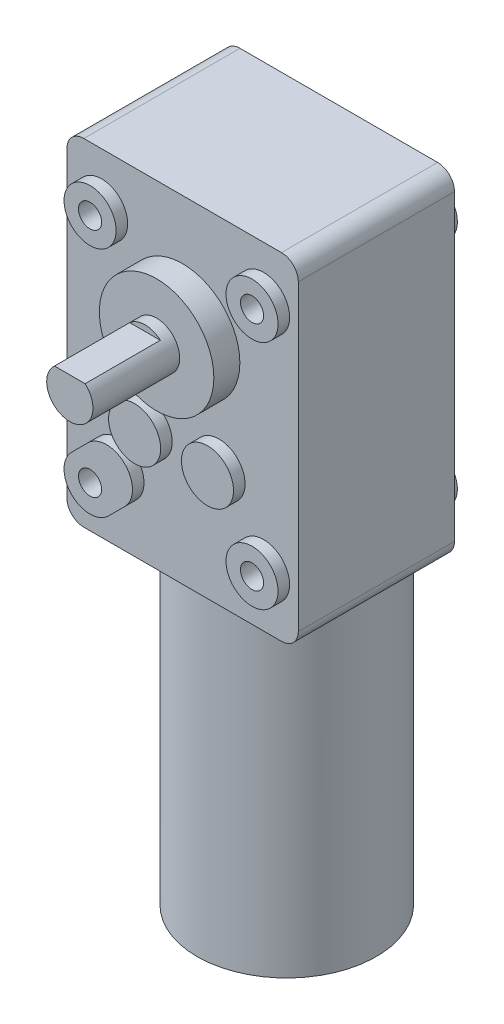
from build123d import *

# Parameters (mm, degrees)
SKETCH1_W           = 40
SKETCH1_H           = 58.200000762
BOSS_EXTRUDE1_DEPTH = 27
SKETCH2_R           = 15.499999921
BOSS_EXTRUDE2_DEPTH = 57
SKETCH3_R           = 9.900000829
BOSS_EXTRUDE3_DEPTH = 4.5
SKETCH4_R           = 3.999999654
BOSS_EXTRUDE4_DEPTH = 15
CUT_EXTRUDE1_DEPTH  = 13
BOSS_EXTRUDE5_DEPTH = 2
BOSS_EXTRUDE6_DEPTH = 2
BOSS_EXTRUDE7_DEPTH = 2
SKETCH9_W           = 4.500000339
SKETCH9_H           = 2
SKETCH10_W          = 4.500000226
SKETCH10_H          = 2
SKETCH11_W          = 4.499999816
SKETCH11_H          = 2
SKETCH12_W          = 4.500000657
SKETCH12_H          = 2
SKETCH13_W          = 4.49999985
SKETCH13_H          = 2
SKETCH14_W          = 9.899999781
SKETCH14_H          = 4.5
SKETCH15_W          = 4.500000004
SKETCH15_H          = 2
SKETCH16_W          = 4.49999905
SKETCH16_H          = 2
SKETCH17_W          = 4.499999637
SKETCH17_H          = 2
SKETCH18_W          = 4.500001132
SKETCH18_H          = 2
SKETCH19_W          = 4.499999489
SKETCH19_H          = 2
FILLET1_R           = 2.913033302
SKETCH20_R          = 2
CUT_EXTRUDE2_DEPTH  = 5


with BuildPart() as part:
    # Sketch1 → Boss-Extrude1 (new body)
    with BuildSketch(Plane(origin=(0, 0, 171), x_dir=(-1, 0, 0), z_dir=(0, 0, -1))):
        with Locations((-152.219146729, 79.232439518)):
            Rectangle(SKETCH1_W, SKETCH1_H)
    extrude(amount=-BOSS_EXTRUDE1_DEPTH)

    # Sketch2 → Boss-Extrude2 (add)
    with BuildSketch(Plane.XZ.offset(-50.132439137)):
        with Locations((152.219146662, 180.000000025)):
            Circle(SKETCH2_R)
    extrude(amount=BOSS_EXTRUDE2_DEPTH)

    # Sketch3 → Boss-Extrude3 (add)
    with BuildSketch(Plane.XY.offset(198)):
        with Locations((152.21914569, 88.232439899)):
            Circle(SKETCH3_R)
    extrude(amount=BOSS_EXTRUDE3_DEPTH)

    # Sketch4 → Boss-Extrude4 (add)
    with BuildSketch(Plane.XY.offset(202.5)):
        with Locations((152.219146674, 88.232439899)):
            Circle(SKETCH4_R)
    extrude(amount=BOSS_EXTRUDE4_DEPTH)

    # Sketch5 → Cut-Extrude1 (cut)
    with BuildSketch(Plane.XY.offset(217.5)):
        with BuildLine():
            Line((149.573395252, 91.232439899), (154.864898205, 91.232439899))
            ThreePointArc((154.864898205, 91.232439899), (152.219146729, 92.232440009), (149.573395252, 91.232439899))
        make_face()
    extrude(amount=-CUT_EXTRUDE1_DEPTH, mode=Mode.SUBTRACT)

    # Sketch6 → Boss-Extrude5 (add)
    with BuildSketch(Plane.XY.offset(198)):
        with BuildLine():
            Line((135.03716583, 62.314419458), (137.865592743, 65.142846371))
            ThreePointArc((137.865592743, 65.142846371), (144.229553368, 65.142846505), (144.22955377, 58.778885881))
            Line((144.22955377, 58.778885881), (141.401127095, 55.95045873))
            ThreePointArc((141.401127095, 55.95045873), (135.037165964, 55.950458327), (135.03716583, 62.314419458))
        make_face()
    extrude(amount=BOSS_EXTRUDE5_DEPTH)

    # Sketch7 → Boss-Extrude6 (add)
    with BuildSketch(Plane(origin=(0, 0, 171), x_dir=(-1, 0, 0), z_dir=(0, 0, -1))):
        with BuildLine():
            ThreePointArc((-142.483799553, 57.696214596), (-144.229553379, 65.142847459), (-136.782921252, 63.397090493))
            ThreePointArc((-136.782921252, 63.397090493), (-135.037167167, 55.950457372), (-142.483799553, 57.696214596))
        make_face()
    extrude(amount=BOSS_EXTRUDE6_DEPTH)

    # Sketch8 → Boss-Extrude7 (add)
    with BuildSketch(Plane.XZ.offset(6.867560863)):
        with BuildLine():
            Line((158.212552085, 179.71876642), (158.159881829, 179.158770706))
            ThreePointArc((158.159881829, 179.158770706), (146.245510806, 180.561848666), (158.212552085, 179.71876642))
        make_face()
    extrude(amount=BOSS_EXTRUDE7_DEPTH)

    # Sketch9 → Revolve1 (revolve)
    with BuildSketch(Plane.XZ.offset(-59.132439085)):
        with Locations((168.469147961, 170)):
            Rectangle(SKETCH9_W, SKETCH9_H)
    revolve(axis=Axis((166.219147791, 59.132439085, 171), (0, 0, -1)))

    # Sketch10 → Revolve2 (revolve)
    with BuildSketch(Plane.XZ.offset(-99.132437815)):
        with Locations((140.469147187, 170)):
            Rectangle(SKETCH10_W, SKETCH10_H)
    revolve(axis=Axis((138.219147074, 99.132437815, 171), (0, 0, -1)))

    # Sketch11 → Revolve3 (revolve)
    with BuildSketch(Plane.XZ.offset(-70.532439222)):
        with Locations((160.769146188, 170)):
            Rectangle(SKETCH11_W, SKETCH11_H)
    revolve(axis=Axis((158.51914628, 70.532439222, 171), (0, 0, -1)))

    # Sketch12 → Revolve4 (revolve)
    with BuildSketch(Plane.XZ.offset(-99.132437815)):
        with Locations((168.46914727, 170)):
            Rectangle(SKETCH12_W, SKETCH12_H)
    revolve(axis=Axis((166.219146941, 99.132437815, 171), (0, 0, -1)))

    # Sketch13 → Revolve5 (revolve)
    with BuildSketch(Plane.XZ.offset(-70.532439222)):
        with Locations((148.16914686, 170)):
            Rectangle(SKETCH13_W, SKETCH13_H)
    revolve(axis=Axis((145.919146935, 70.532439222, 171), (0, 0, -1)))

    # Sketch14 → Revolve6 (revolve)
    with BuildSketch(Plane.XZ.offset(-88.232439085)):
        with Locations((157.169146737, 168.75)):
            Rectangle(SKETCH14_W, SKETCH14_H)
    revolve(axis=Axis((152.219146846, 88.232439085, 171), (0, 0, -1)))

    # Sketch15 → Revolve7 (revolve)
    with BuildSketch(Plane(origin=(0, 59.332439899, 0), x_dir=(1, 0, 0), z_dir=(0, 1, 0))):
        with Locations((168.469147213, -199)):
            Rectangle(SKETCH15_W, SKETCH15_H)
    revolve(axis=Axis((166.219147211, 59.332439899, 198), (0, 0, 1)))

    # Sketch16 → Revolve8 (revolve)
    with BuildSketch(Plane(origin=(0, 99.332439899, 0), x_dir=(1, 0, 0), z_dir=(0, 1, 0))):
        with Locations((168.469146681, -199)):
            Rectangle(SKETCH16_W, SKETCH16_H)
    revolve(axis=Axis((166.219147156, 99.332439899, 198), (0, 0, 1)))

    # Sketch17 → Revolve9 (revolve)
    with BuildSketch(Plane(origin=(0, 70.532438002, 0), x_dir=(1, 0, 0), z_dir=(0, 1, 0))):
        with Locations((160.769147041, -199)):
            Rectangle(SKETCH17_W, SKETCH17_H)
    revolve(axis=Axis((158.519147223, 70.532438002, 198), (0, 0, 1)))

    # Sketch18 → Revolve10 (revolve)
    with BuildSketch(Plane(origin=(0, 99.332439899, 0), x_dir=(1, 0, 0), z_dir=(0, 1, 0))):
        with Locations((140.469146163, -199)):
            Rectangle(SKETCH18_W, SKETCH18_H)
    revolve(axis=Axis((138.219145597, 99.332439899, 198), (0, 0, 1)))

    # Sketch19 → Revolve11 (revolve)
    with BuildSketch(Plane(origin=(0, 70.532438002, 0), x_dir=(1, 0, 0), z_dir=(0, 1, 0))):
        with Locations((148.169147032, -199)):
            Rectangle(SKETCH19_W, SKETCH19_H)
    revolve(axis=Axis((145.919147287, 70.532438002, 198), (0, 0, 1)))

    # Fillet1
    fillet1_edges = [part.edges().sort_by_distance(p)[0] for p in [
        (132.219146729, 108.332439899, 184.5),
        (132.219146729, 50.132439137, 184.5),
        (172.219146729, 50.132439137, 184.5),
        (172.219146729, 108.332439899, 184.5),
    ]]
    fillet(fillet1_edges, radius=FILLET1_R)

    # Sketch20 → Cut-Extrude2 (cut)
    with BuildSketch(Plane.XY.offset(200)):
        with Locations((138.219145597, 99.332439899)):
            Circle(SKETCH20_R)
        with Locations((166.219147211, 99.332439899)):
            Circle(SKETCH20_R)
        with Locations((138.219145597, 59.332439899)):
            Circle(SKETCH20_R)
        with Locations((166.219147211, 59.332439899)):
            Circle(SKETCH20_R)
    extrude(amount=-CUT_EXTRUDE2_DEPTH, mode=Mode.SUBTRACT)


solid = part.part
